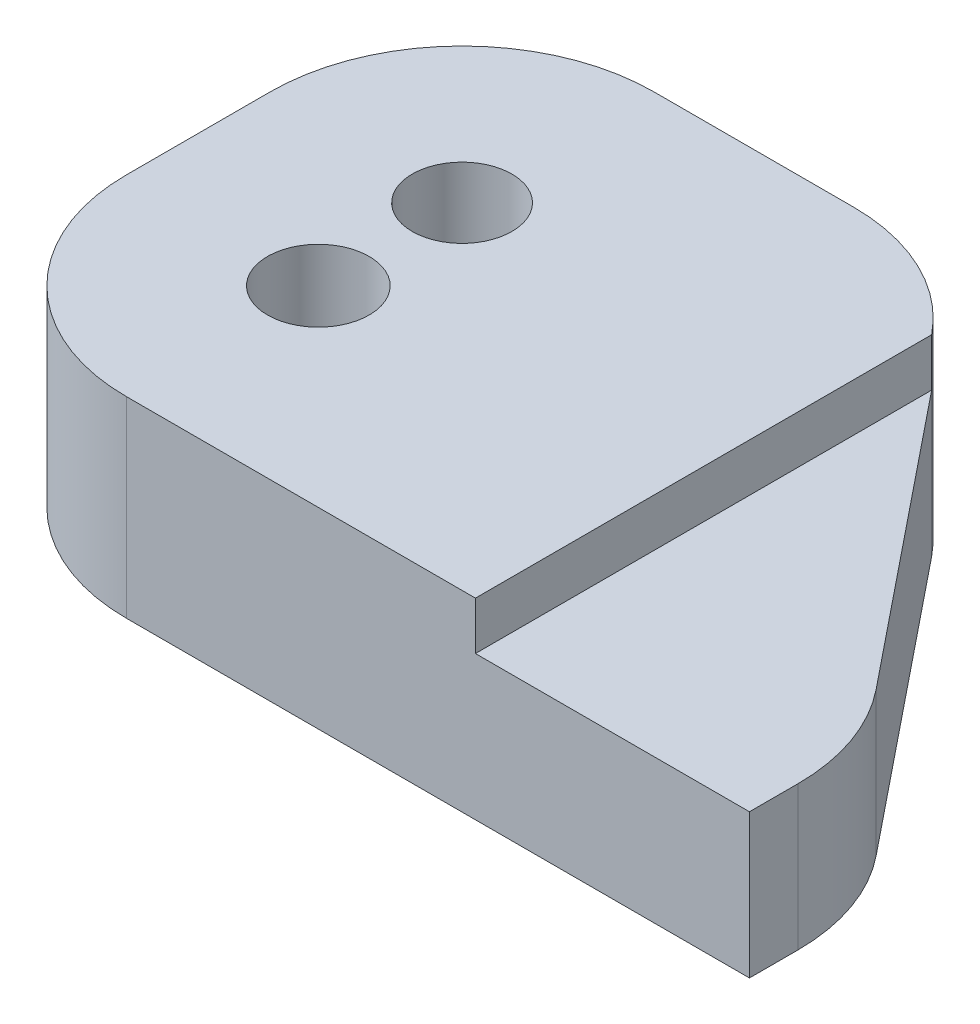
from build123d import *

# Parameters (mm, degrees)
BOSS_EXTRUDE1_DEPTH = 19.05
FILLET1_R           = 25.4
BOSS_EXTRUDE2_DEPTH = 6.35
SKETCH4_R           = 6.721788933
SKETCH4_R_2         = 6.590945077
CUT_EXTRUDE3_DEPTH  = 26.4


with BuildPart() as part:
    # Sketch1 → Boss-Extrude1 (new body)
    with BuildSketch(Plane(origin=(0, 0, 0), x_dir=(1, 0, 0), z_dir=(0, 1, 0))):
        Polygon((10.04026689, 34.907603773), (53.917892581, -19.499033471), (53.917892581, -34.907603773), (-53.917892581, -34.907603773), (-53.917892581, 34.907603773), align=None)
    extrude(amount=BOSS_EXTRUDE1_DEPTH)

    # Fillet1
    fillet1_edges = [part.edges().sort_by_distance(p)[0] for p in [
        (-53.917892581, 9.525, -34.907603773),
        (10.04026689, 9.525, -34.907603773),
        (53.917892581, 9.525, 19.499033471),
        (-53.917892581, 9.525, 34.907603773),
    ]]
    fillet(fillet1_edges, radius=FILLET1_R)

    # Sketch3 → Boss-Extrude2 (add)
    with BuildSketch(Plane(origin=(0, 19.05, 0), x_dir=(1, 0, 0), z_dir=(0, 1, 0))):
        with BuildLine():
            Line((17.665332694, 25.452803459), (17.665332694, -34.907603773))
            Line((17.665332694, -34.907603773), (-28.517892581, -34.907603773))
            ThreePointArc((-28.517892581, -34.907603773), (-46.478404823, -27.468116015), (-53.917892581, -9.507603773))
            Line((-53.917892581, -9.507603773), (-53.917892581, 9.507603773))
            ThreePointArc((-53.917892581, 9.507603773), (-46.478404823, 27.468116015), (-28.517892581, 34.907603773))
            Line((-28.517892581, 34.907603773), (-2.106126711, 34.907603773))
            ThreePointArc((-2.106126711, 34.907603773), (8.851791157, 32.422315991), (17.665332694, 25.452803459))
        make_face()
    extrude(amount=BOSS_EXTRUDE2_DEPTH)

    # Sketch4 → Cut-Extrude3 (cut, through all)
    with BuildSketch(Plane(origin=(0, 25.4, 0), x_dir=(1, 0, 0), z_dir=(0, 1, 0))):
        with Locations(Location((-28.517892581, -9.507603773, 0), (0, 0, 270))):  # turned: the seam where the file's is
            Circle(SKETCH4_R)
        with Locations(Location((-28.517892581, 9.507603773, 0), (0, 0, 270))):  # turned: the seam where the file's is
            Circle(SKETCH4_R_2)
    extrude(amount=-CUT_EXTRUDE3_DEPTH, mode=Mode.SUBTRACT)


solid = part.part
